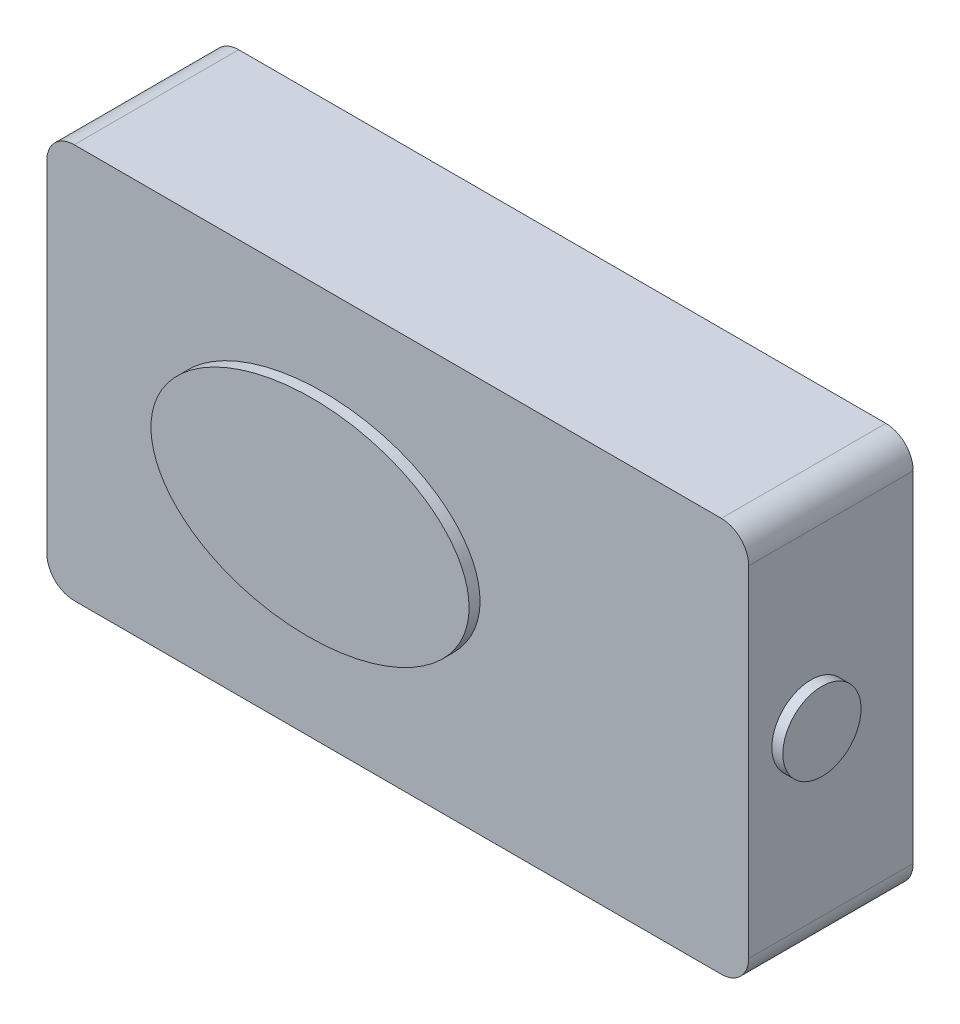
from build123d import *

# Parameters (mm, degrees)
SKETCH1_W           = 64
SKETCH1_H           = 36
BOSS_EXTRUDE1_DEPTH = 15
FILLET1_R           = 2.5
SKETCH2_RX          = 14.501940206
SKETCH2_RY          = 9.5
BOSS_EXTRUDE2_DEPTH = 1
SKETCH3_R           = 3.563696192
BOSS_EXTRUDE3_DEPTH = 1


with BuildPart() as part:
    # Sketch1 → Boss-Extrude1 (new body)
    with BuildSketch(Plane.XY):
        with Locations((2.310469314, -0.093862816)):
            Rectangle(SKETCH1_W, SKETCH1_H)
    extrude(amount=BOSS_EXTRUDE1_DEPTH)

    # Fillet1
    fillet1_edges = [part.edges().sort_by_distance(p)[0] for p in [
        (-29.689530686, 17.906137184, 7.5),
        (34.310469314, 17.906137184, 7.5),
        (34.310469314, -18.093862816, 7.5),
        (-29.689530686, -18.093862816, 7.5),
    ]]
    fillet(fillet1_edges, radius=FILLET1_R)

    # Sketch2 → Boss-Extrude2 (add)
    with BuildSketch(Plane.XY.offset(15)):
        with Locations(Location((-4.689530686, 0.237212403), (0, 0, 0.937245327))):
            Ellipse(SKETCH2_RX, SKETCH2_RY)
    extrude(amount=BOSS_EXTRUDE2_DEPTH)

    # Sketch3 → Boss-Extrude3 (add)
    with BuildSketch(Plane(origin=(34.310469314, 0, 0), x_dir=(0, 0, -1), z_dir=(1, 0, 0))):
        with Locations((-9.325073978, 0)):
            Circle(SKETCH3_R)
    extrude(amount=BOSS_EXTRUDE3_DEPTH)


solid = part.part
